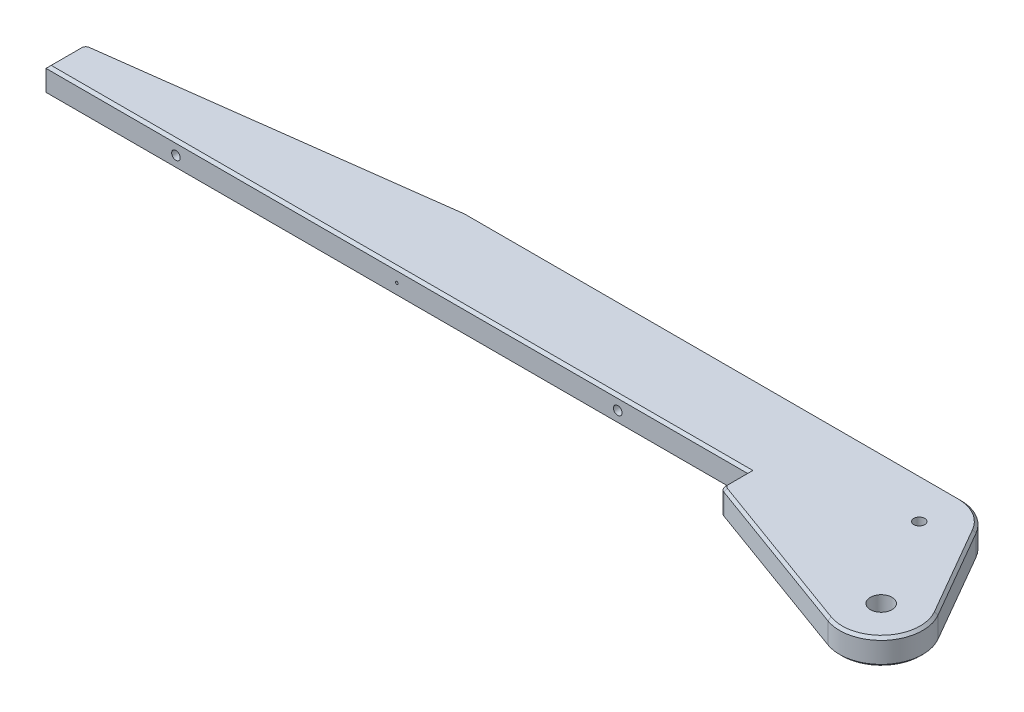
from build123d import *

# Parameters (mm, degrees)
BOSS_EXTRUDE1_DEPTH       = 5
M5X0_8_TAPPED_HOLE1_D     = 4.2
SKETCH5_R                 = 4.15
CUT_EXTRUDE1_DEPTH        = 6
M4X0_7_TAPPED_HOLE1_D     = 3.3
M4X0_7_TAPPED_HOLE1_DEPTH = 15
M4X0_7_TAPPED_HOLE1_TIP   = 0.991420021
FILLET1_R                 = 2.5
CHAMFER1_SIZE             = 1
F_1_0MM_DOWEL_HOLE1_D     = 1
F_1_0MM_DOWEL_HOLE1_DEPTH = 5
F_1_0MM_DOWEL_HOLE1_TIP   = 0.30043031


with BuildPart() as part:
    # Sketch2 → Boss-Extrude1 (new body, symmetric)
    with BuildSketch(Plane(origin=(0, 0, 0), x_dir=(1, 0, 0), z_dir=(0, 1, 0))):
        with BuildLine():
            Line((-210, 50.641016151), (-20, 50.641016151))
            ThreePointArc((-20, 50.641016151), (-12, 48.497422612), (-6.143593539, 42.641016151))
            Line((-6.143593539, 42.641016151), (13.856406461, 8))
            ThreePointArc((13.856406461, 8), (12.25671109, -10.284601755), (-5.472322293, -15.035081933))
            Line((-5.472322293, -15.035081933), (-70, 8.451072039))
            Line((-70, 8.451072039), (-70, 18.641016151))
            Line((-70, 18.641016151), (-340, 18.641016151))
            Line((-340, 18.641016151), (-340, 33.641016151))
            Line((-340, 33.641016151), (-210, 50.641016151))
        make_face()
    extrude(amount=BOSS_EXTRUDE1_DEPTH, both=True)

    # M5x0.8 Tapped Hole1 (through all)
    with Locations(Plane(origin=(0, 5, 0), x_dir=(1, 0, 0), z_dir=(0, 1, 0))):
        with Locations((-20, 34.641016151), (0, 0)):
            Hole(M5X0_8_TAPPED_HOLE1_D / 2)

    # Sketch5 → Cut-Extrude1 (cut)
    with BuildSketch(Plane(origin=(0, 5, 0), x_dir=(1, 0, 0), z_dir=(0, 1, 0))):
        Circle(SKETCH5_R)
    extrude(amount=-CUT_EXTRUDE1_DEPTH, mode=Mode.SUBTRACT)

    # M4x0.7 Tapped Hole1
    with Locations(Plane.XY.offset(-18.641016151)):
        with Locations((-290, 0), (-120, 0)):
            Hole(M4X0_7_TAPPED_HOLE1_D / 2, depth=M4X0_7_TAPPED_HOLE1_DEPTH)
            with Locations((0, 0, -(M4X0_7_TAPPED_HOLE1_DEPTH + M4X0_7_TAPPED_HOLE1_TIP / 2))):  # 118° drill point
                Cone(0, M4X0_7_TAPPED_HOLE1_D / 2, M4X0_7_TAPPED_HOLE1_TIP, mode=Mode.SUBTRACT)

    # Fillet1
    fillet1_edges = [part.edges().sort_by_distance(p)[0] for p in [
        (-70, 0, -8.451072039),
        (-340, 0, -33.641016151),
        (-210, 0, -50.641016151),
    ]]
    fillet(fillet1_edges, radius=FILLET1_R)

    # Chamfer1
    chamfer1_edges = [part.edges().sort_by_distance(p)[0] for p in [
        (-70, -5, -14.421303518),
        (-205, -5, -18.641016151),
        (-114.918615686, -5, -50.641016151),
        (-12, -5, -48.497422612),
        (-205, 5, -18.641016151),
        (-70, 5, -14.421303518),
        (12.25671109, 5, 10.284601755),
        (3.856406461, 5, -25.320508076),
        (-12, 5, -48.497422612),
        (-273.992778821, -5, -42.27272969),
        (-273.992778821, 5, -42.27272969),
        (-36.913686326, -5, 3.5913613),
        (-340, -5, -25.043835126),
        (-69.547880111, -5, -8.767649794),
        (-339.37888369, -5, -33.095834527),
        (-209.999656106, -5, -50.635734213),
        (-340, 5, -25.043835126),
        (-36.913686326, 5, 3.5913613),
        (-69.547880111, 5, -8.767649794),
        (-339.37888369, 5, -33.095834527),
        (-209.999656106, 5, -50.635734213),
        (-114.918615686, 5, -50.641016151),
        (3.856406461, -5, -25.320508076),
        (12.25671109, -5, 10.284601755),
    ]]
    chamfer(chamfer1_edges, length=CHAMFER1_SIZE)

    # Ø1.0mm Dowel Hole1
    with Locations(Plane.XY.offset(-18.641016151)):
        with Locations((-205, 0)):
            Hole(F_1_0MM_DOWEL_HOLE1_D / 2, depth=F_1_0MM_DOWEL_HOLE1_DEPTH)
            with Locations((0, 0, -(F_1_0MM_DOWEL_HOLE1_DEPTH + F_1_0MM_DOWEL_HOLE1_TIP / 2))):  # 118° drill point
                Cone(0, F_1_0MM_DOWEL_HOLE1_D / 2, F_1_0MM_DOWEL_HOLE1_TIP, mode=Mode.SUBTRACT)


solid = part.part
